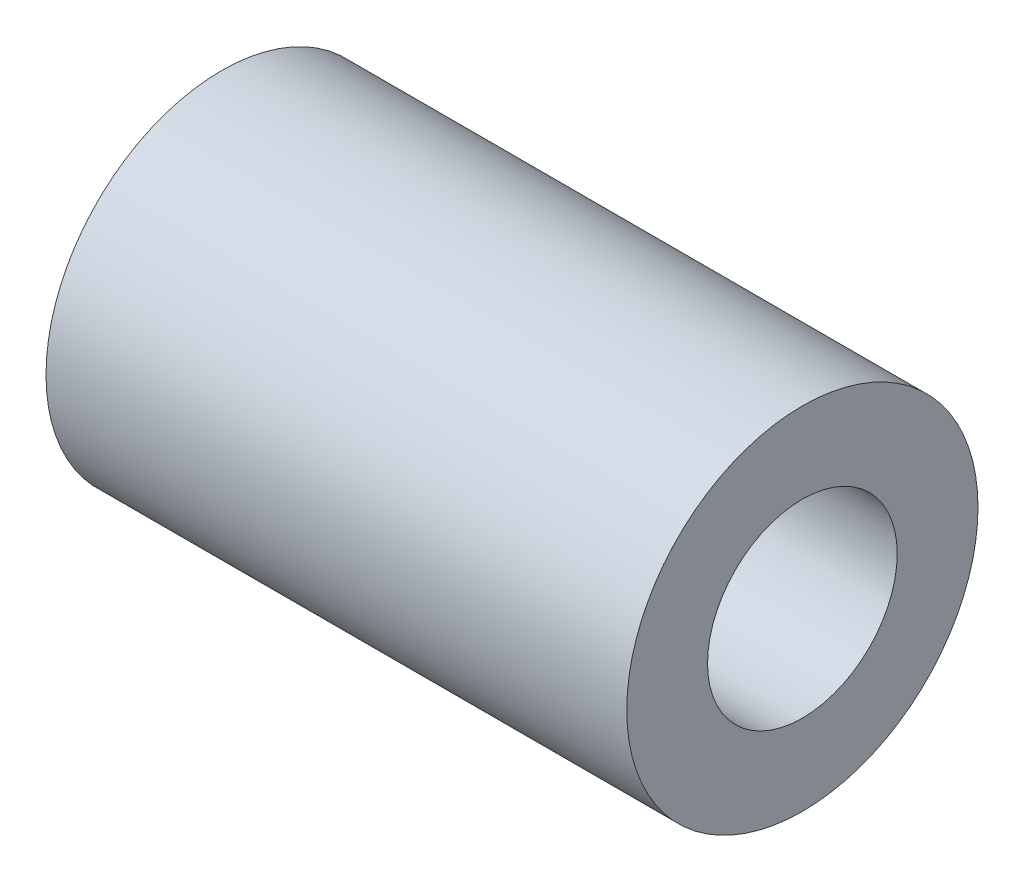
from build123d import *

# Parameters (mm, degrees)
ESQUISSE1_R        = 6.35
ESQUISSE1_R_2      = 3.429
BOSS_EXTRU_1_DEPTH = 21


with BuildPart() as part:
    # Esquisse1 → Boss.-Extru.1 (new body)
    with BuildSketch(Plane(origin=(0, 0, 0), x_dir=(0, 0, -1), z_dir=(1, 0, 0))):
        Circle(ESQUISSE1_R)
        Circle(ESQUISSE1_R_2, mode=Mode.SUBTRACT)
    extrude(amount=-BOSS_EXTRU_1_DEPTH)


solid = part.part
